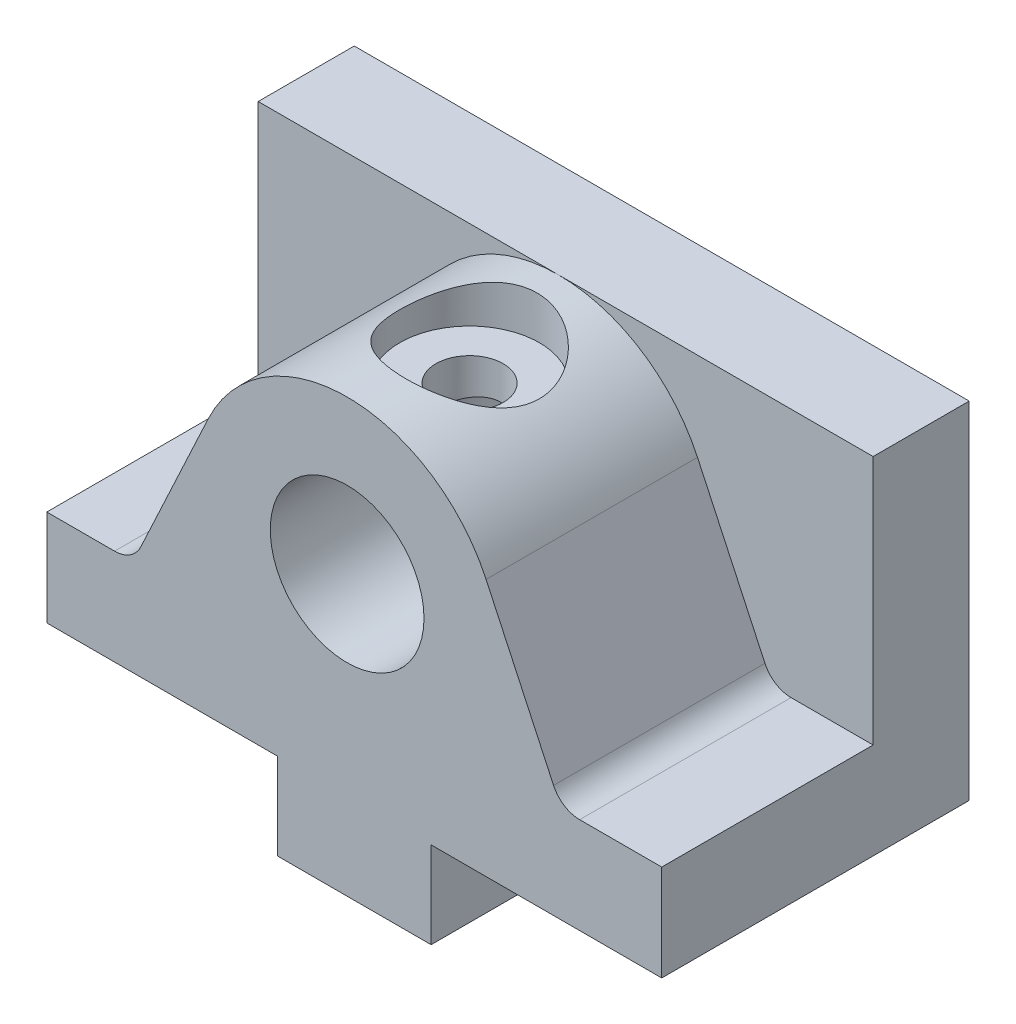
from build123d import *

# Parameters (mm, degrees)
SKETCH1_W                               = 64
SKETCH1_H                               = 32
BOSS_EXTRUDE1_DEPTH                     = 10
SKETCH4_W                               = 64
SKETCH4_H                               = 10
BOSS_EXTRUDE3_DEPTH                     = 26
BOSS_EXTRUDE4_DEPTH                     = 22
FILLET1_R                               = 3
SKETCH6_W                               = 16
SKETCH6_H                               = 9
BOSS_EXTRUDE5_DEPTH                     = 32
CBORE_FOR_M6_HEX_HEAD_BOLT1_D           = 7
CBORE_FOR_M6_HEX_HEAD_BOLT1_DEPTH       = 15
CBORE_FOR_M6_HEX_HEAD_BOLT1_CBORE_D     = 14.55
CBORE_FOR_M6_HEX_HEAD_BOLT1_CBORE_DEPTH = 4.38
CBORE_FOR_M6_HEX_HEAD_BOLT1_TIP         = 2.103012167
SKETCH12_R                              = 8
CUT_EXTRUDE1_DEPTH                      = 24
TAP_DRILL_FOR_M6X1_0_TAP1_D             = 5
TAP_DRILL_FOR_M6X1_0_TAP1_DEPTH         = 16
TAP_DRILL_FOR_M6X1_0_TAP1_TIP           = 1.502151548


with BuildPart() as part:
    # Sketch1 → Boss-Extrude1 (new body)
    with BuildSketch(Plane(origin=(0, 0, 0), x_dir=(1, 0, 0), z_dir=(0, 1, 0))):
        Rectangle(SKETCH1_W, SKETCH1_H)
    extrude(amount=BOSS_EXTRUDE1_DEPTH)

    # Sketch4 → Boss-Extrude3 (add)
    with BuildSketch(Plane(origin=(0, 10, 0), x_dir=(1, 0, 0), z_dir=(0, 1, 0))):
        with Locations((0, 11)):
            Rectangle(SKETCH4_W, SKETCH4_H)
    extrude(amount=BOSS_EXTRUDE3_DEPTH)

    # Sketch5 → Boss-Extrude4 (add)
    with BuildSketch(Plane.XY.offset(-6)):
        with BuildLine():
            Line((-15.204681896, 26.786179615), (-23.032206002, 10))
            Line((-23.032206002, 10), (21.548444147, 10))
            Line((21.548444147, 10), (13.720920041, 26.786179615))
            ThreePointArc((13.720920041, 26.786179615), (-0.741880927, 36), (-15.204681896, 26.786179615))
        make_face()
    extrude(amount=BOSS_EXTRUDE4_DEPTH)

    # Fillet1
    fillet1_edges = [part.edges().sort_by_distance(p)[0] for p in [
        (21.548444147, 10, 5),
        (-23.032206002, 10, 5),
    ]]
    fillet(fillet1_edges, radius=FILLET1_R)

    # Sketch6 → Boss-Extrude5 (add)
    with BuildSketch(Plane.XY.offset(16)):
        with Locations((0, -4.5)):
            Rectangle(SKETCH6_W, SKETCH6_H)
    extrude(amount=-BOSS_EXTRUDE5_DEPTH)

    # CBORE for M6 Hex Head Bolt1
    with Locations(Plane(origin=(0, 36, 0), x_dir=(1, 0, 0), z_dir=(0, 1, 0))):
        with Locations((0, -4)):
            CounterBoreHole(CBORE_FOR_M6_HEX_HEAD_BOLT1_D / 2, CBORE_FOR_M6_HEX_HEAD_BOLT1_CBORE_D / 2, CBORE_FOR_M6_HEX_HEAD_BOLT1_CBORE_DEPTH, depth=CBORE_FOR_M6_HEX_HEAD_BOLT1_DEPTH)
            with Locations((0, 0, -(CBORE_FOR_M6_HEX_HEAD_BOLT1_DEPTH + CBORE_FOR_M6_HEX_HEAD_BOLT1_TIP / 2))):  # 118° drill point
                Cone(0, CBORE_FOR_M6_HEX_HEAD_BOLT1_D / 2, CBORE_FOR_M6_HEX_HEAD_BOLT1_TIP, mode=Mode.SUBTRACT)

    # Sketch12 → Cut-Extrude1 (cut)
    with BuildSketch(Plane.XY.offset(16)):
        with Locations((-0.741880927, 20.042064765)):
            Circle(SKETCH12_R)
    extrude(amount=-CUT_EXTRUDE1_DEPTH, mode=Mode.SUBTRACT)

    # Tap Drill for M6x1.0 Tap1
    with Locations(Plane(origin=(0, -9, 0), x_dir=(-1, 0, 0), z_dir=(0, -1, 0))):
        with Locations((0, -8), (0, 8)):
            Hole(TAP_DRILL_FOR_M6X1_0_TAP1_D / 2, depth=TAP_DRILL_FOR_M6X1_0_TAP1_DEPTH)
            with Locations((0, 0, -(TAP_DRILL_FOR_M6X1_0_TAP1_DEPTH + TAP_DRILL_FOR_M6X1_0_TAP1_TIP / 2))):  # 118° drill point
                Cone(0, TAP_DRILL_FOR_M6X1_0_TAP1_D / 2, TAP_DRILL_FOR_M6X1_0_TAP1_TIP, mode=Mode.SUBTRACT)


solid = part.part
